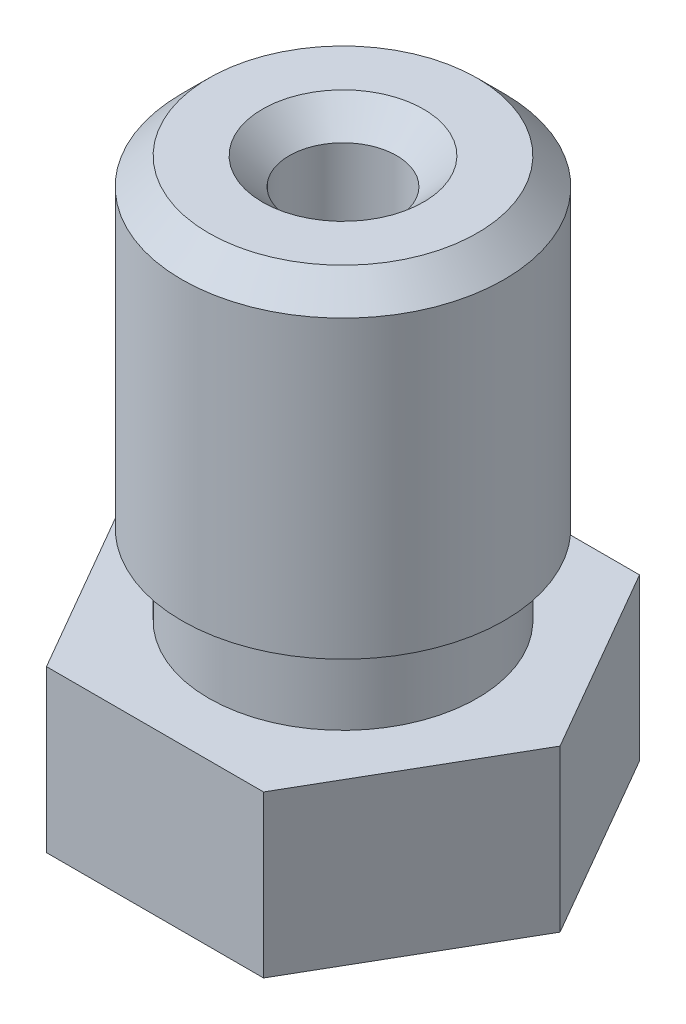
from build123d import *

# Parameters (mm, degrees)
BOSS_EXTRUDE1_DEPTH = 3
CHAMFER1_SIZE       = 0.5


with BuildPart() as part:
    # Sketch1 → Boss-Extrude1 (new body)
    with BuildSketch(Plane.XZ):
        Polygon((-2.020725942, 3.5), (-4.041451884, 0), (-2.020725942, -3.5), (2.020725942, -3.5), (4.041451884, 0), (2.020725942, 3.5), align=None)
    extrude(amount=-BOSS_EXTRUDE1_DEPTH)

    # Sketch2 → Revolve1 (revolve)
    with BuildSketch(Plane(origin=(0, 0, 0), x_dir=(-1, 0, 0), z_dir=(0, 0, -1))):
        Polygon((-2.5, 3), (0, 3), (0, 10.5), (-3, 10.5), (-3, 4.5), (-2.5, 4.5), align=None)
    revolve(axis=Axis((0, 3, 0), (0, 1, 0)))

    # Sketch3 → Revolve2 (revolve)
    with BuildSketch(Plane.XY):
        Polygon((2.5, 0), (0, 0), (0, -2), (0.5, -2), align=None)
    revolve(axis=Axis((0, 0, 0), (0, -1, 0)))

    # Sketch4 → Cut-Revolve1 (revolve, cut)
    with BuildSketch(Plane(origin=(0, 0, 0), x_dir=(-1, 0, 0), z_dir=(0, 0, -1))):
        Polygon((-0.25, -2), (0, -2), (0, 10.5), (-1, 10.5), (-1, 0), (-0.75, -0.227272727), (-0.75, -0.7), (-0.25, -1.2), align=None)
    revolve(axis=Axis((0, -2, 0), (0, 1, 0)), mode=Mode.SUBTRACT)

    # Chamfer1
    chamfer1_edges = [part.edges().sort_by_distance(p)[0] for p in [
        (-3, 10.5, 0),
        (-1, 10.5, 0),
    ]]
    chamfer(chamfer1_edges, length=CHAMFER1_SIZE)


solid = part.part
